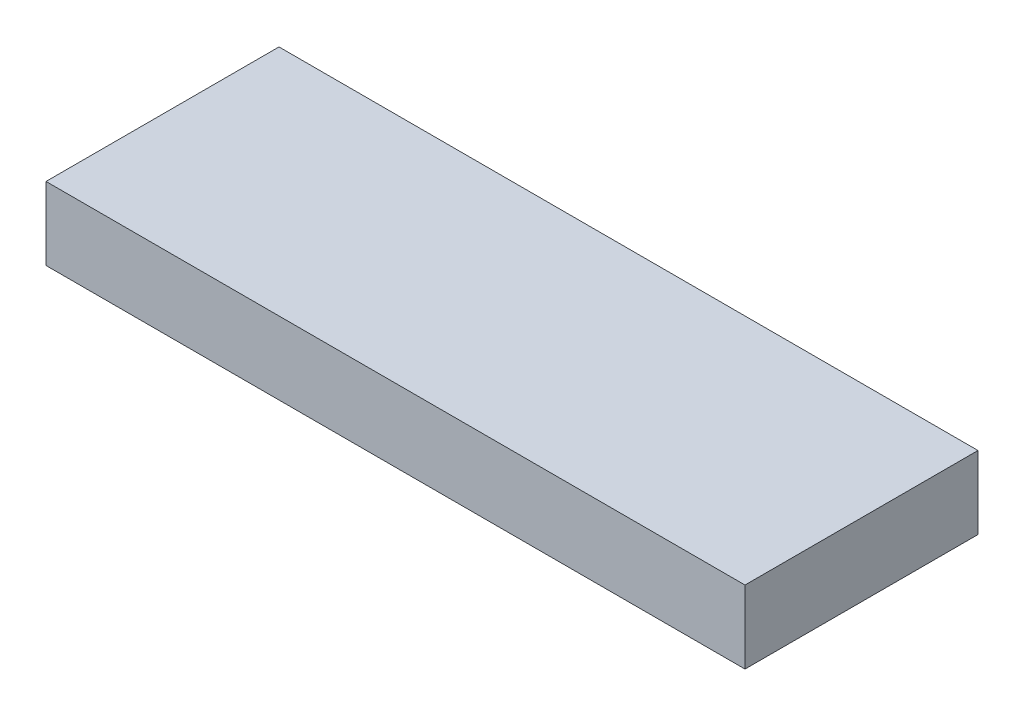
from build123d import *

# Parameters (mm, degrees)
SKETCH1_W           = 609.6
SKETCH1_H           = 203.2
BOSS_EXTRUDE1_DEPTH = 31.75


with BuildPart() as part:
    # Sketch1 → Boss-Extrude1 (new body, symmetric)
    with BuildSketch(Plane(origin=(0, 0, 0), x_dir=(1, 0, 0), z_dir=(0, 1, 0))):
        Rectangle(SKETCH1_W, SKETCH1_H)
    extrude(amount=BOSS_EXTRUDE1_DEPTH, both=True)


solid = part.part
